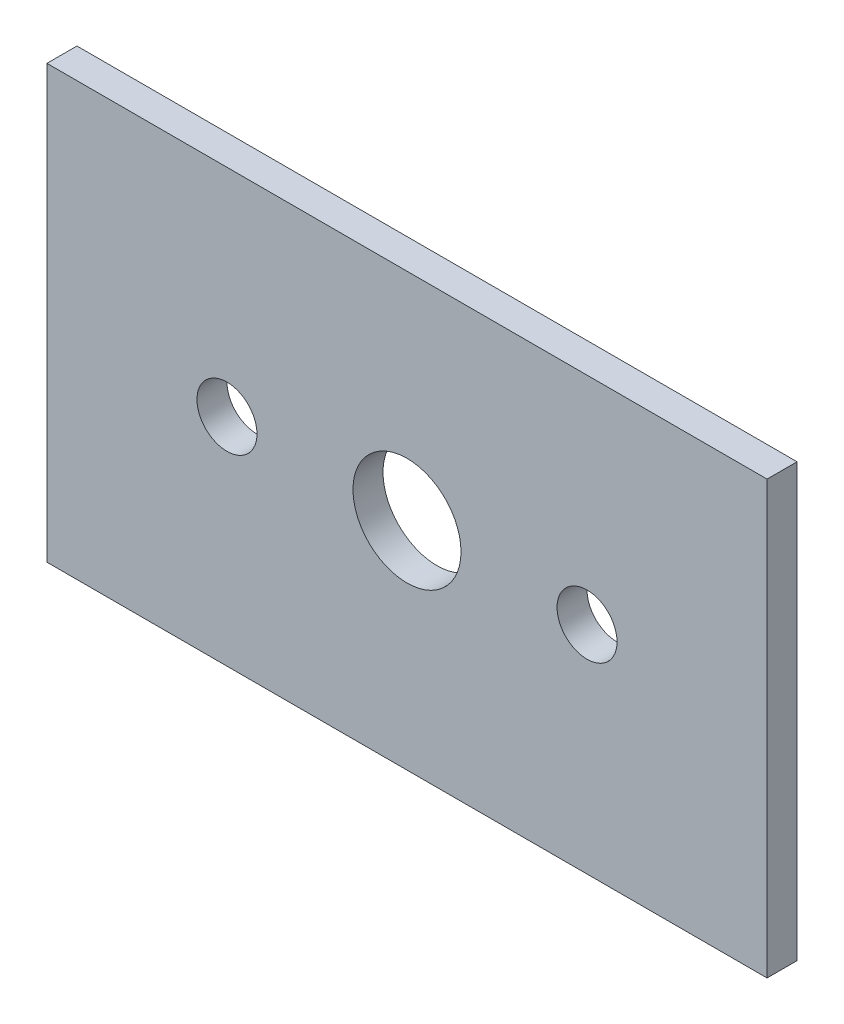
from build123d import *

# Parameters (mm, degrees)
SKETCH1_W           = 152.4
SKETCH1_H           = 91.44
BOSS_EXTRUDE1_DEPTH = 6.35
SKETCH2_R           = 11.43
SKETCH2_R_2         = 6.35
CUT_EXTRUDE1_DEPTH  = 6.35


with BuildPart() as part:
    # Sketch1 → Boss-Extrude1 (new body)
    with BuildSketch(Plane.XY):
        with Locations((76.2, 45.72)):
            Rectangle(SKETCH1_W, SKETCH1_H)
    extrude(amount=BOSS_EXTRUDE1_DEPTH)

    # Sketch2 → Cut-Extrude1 (cut)
    with BuildSketch(Plane.XY.offset(6.35)):
        with Locations((76.2, 45.72)):
            Circle(SKETCH2_R)
        with Locations((114.3, 45.72)):
            Circle(SKETCH2_R_2)
        with Locations((38.1, 45.72)):
            Circle(SKETCH2_R_2)
    extrude(amount=-CUT_EXTRUDE1_DEPTH, mode=Mode.SUBTRACT)


solid = part.part
